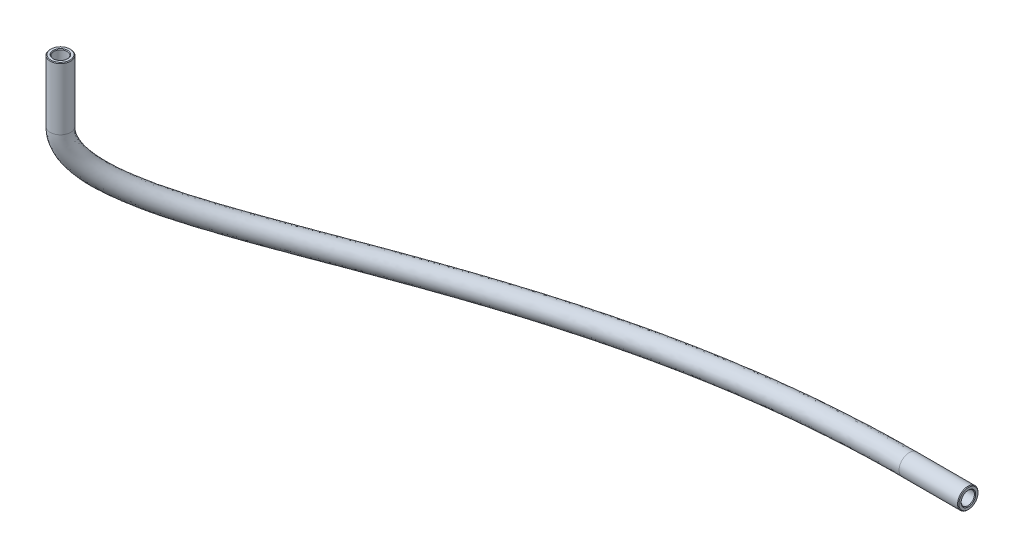
from build123d import *

# Parameters (mm, degrees)
SKETCH1_R     = 2
SKETCH1_R_2   = 1.3
CHAMFER1_SIZE = 0.127


with BuildPart() as part:
    # Sweep1: sweep along a curve in space
    with BuildLine() as sweep1_path:
        Line((249.105, -102.482256564, -40.125), (237.525, -102.482256564, -40.125))
        add(Edge.make_bspline(
            [(237.525, -102.482256564, -40.125), (198.531346094, -102.482256564, -40.125), (145.941364972, -97.0293802, -13.1375), (125.325, -83.12514271, 13.85), (125.325, -74.325, 13.85)],
            knots=[0, 0, 0, 0, 0.517444424, 1, 1, 1, 1], degree=3))
        Line((125.325, -62.125, 13.85), (125.325, -74.325, 13.85))
    # Sketch1 → Sweep1 (sweep)
    with BuildSketch(Plane.ZY.offset(-239.725)):
        with Locations((-40.125, -102.482256564)):
            Circle(SKETCH1_R)
        with Locations((-40.125, -102.482256564)):
            Circle(SKETCH1_R_2, mode=Mode.SUBTRACT)
    sweep(path=sweep1_path.line)

    # Chamfer1
    chamfer1_edges = [part.edges().sort_by_distance(p)[0] for p in [
        (249.105, -102.482256564, -41.425),
        (249.105, -102.482256564, -42.125),
        (124.46019934, -62.125, 12.879371431),
        (123.994537446, -62.125, 12.356725279),
    ]]
    chamfer(chamfer1_edges, length=CHAMFER1_SIZE)


solid = part.part
